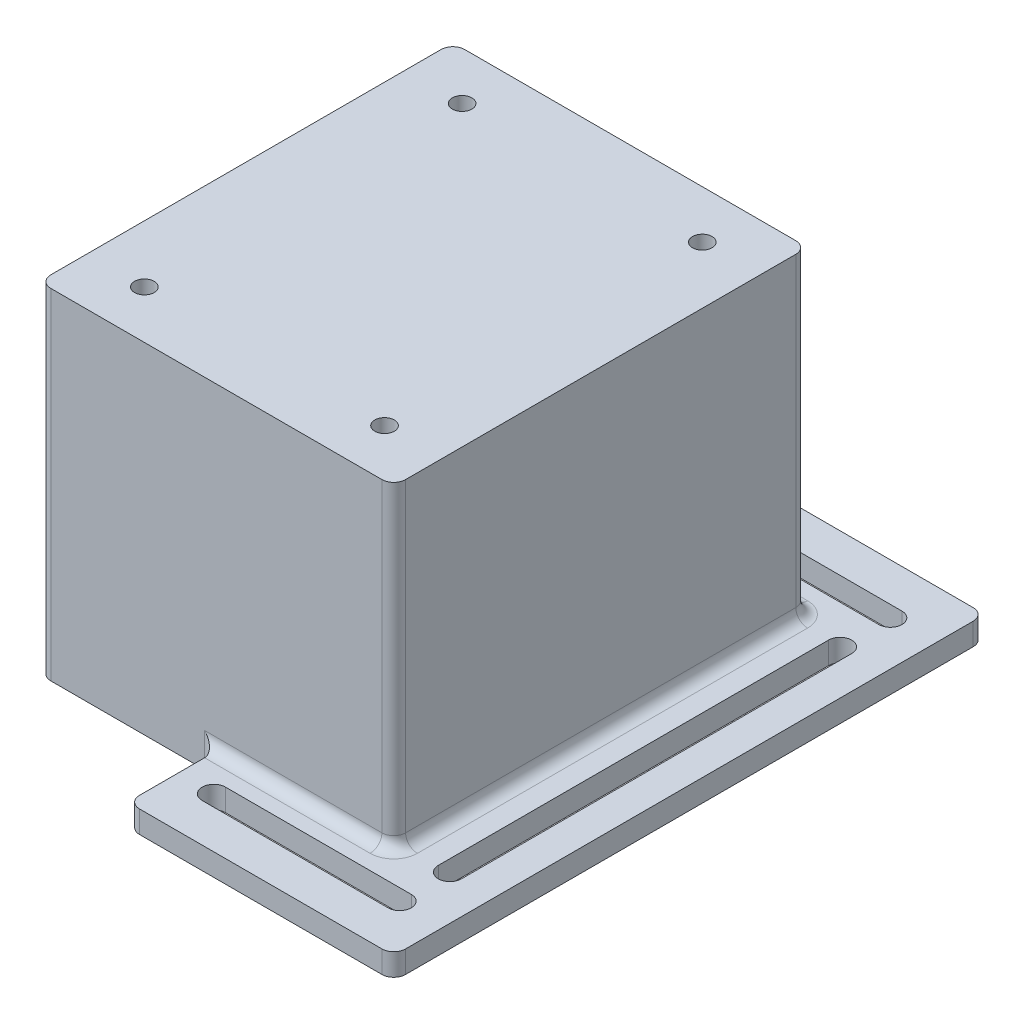
from build123d import *

# Parameters (mm, degrees)
SKETCH1_W           = 76.2
SKETCH1_H           = 88.9
BOSS_EXTRUDE1_DEPTH = 73.025
BOSS_EXTRUDE2_DEPTH = 4.7625
FILLET1_R           = 2.54
CUT_EXTRUDE1_DEPTH  = 5.7625
FILLET2_R           = 2.54
SKETCH4_R           = 2.1
CUT_EXTRUDE2_DEPTH  = 25.4


with BuildPart() as part:
    # Sketch1 → Boss-Extrude1 (new body)
    with BuildSketch(Plane(origin=(0, 0, 0), x_dir=(1, 0, 0), z_dir=(0, 1, 0))):
        with Locations((38.1, 44.45)):
            Rectangle(SKETCH1_W, SKETCH1_H)
    extrude(amount=BOSS_EXTRUDE1_DEPTH)

    # Sketch2 → Boss-Extrude2 (add)
    with BuildSketch(Plane.XZ):
        Polygon((38.1, 0), (38.1, 19.05), (95.25, 19.05), (95.25, -107.95), (38.1, -107.95), (38.1, -88.9), align=None)
    extrude(amount=-BOSS_EXTRUDE2_DEPTH)

    # Fillet1
    fillet1_edges = [part.edges().sort_by_distance(p)[0] for p in [
        (38.1, 2.38125, -107.95),
        (38.1, 2.38125, 19.05),
        (95.25, 2.38125, 19.05),
        (95.25, 2.38125, -107.95),
        (0, 36.5125, -88.9),
        (76.2, 38.89375, -88.9),
        (76.2, 38.89375, 0),
        (0, 36.5125, 0),
    ]]
    fillet(fillet1_edges, radius=FILLET1_R)

    # Sketch3 → Cut-Extrude1 (cut, through all)
    with BuildSketch(Plane(origin=(0, 4.7625, 0), x_dir=(1, 0, 0), z_dir=(0, 1, 0))):
        with BuildLine():
            Line((45.796852287, 99.655), (85.725, 99.655))
            ThreePointArc((85.725, 99.655), (88.225, 97.155), (85.725, 94.655))
            Line((85.725, 94.655), (45.796852287, 94.655))
            ThreePointArc((45.796852287, 94.655), (43.296852287, 97.155), (45.796852287, 99.655))
        make_face()
        with BuildLine():
            Line((45.796852287, -10.755), (85.725, -10.755))
            ThreePointArc((85.725, -10.755), (88.225, -8.255), (85.725, -5.755))
            Line((85.725, -5.755), (45.796852287, -5.755))
            ThreePointArc((45.796852287, -5.755), (43.296852287, -8.255), (45.796852287, -10.755))
        make_face()
        with BuildLine():
            Line((88.225, 86.36), (88.225, 2.54))
            ThreePointArc((88.225, 2.54), (85.725, 0.04), (83.225, 2.54))
            Line((83.225, 2.54), (83.225, 86.36))
            ThreePointArc((83.225, 86.36), (85.725, 88.86), (88.225, 86.36))
        make_face()
    extrude(amount=-CUT_EXTRUDE1_DEPTH, mode=Mode.SUBTRACT)

    # Fillet2
    fillet2_edges = [part.edges().sort_by_distance(p)[0] for p in [
        (55.88, 4.7625, -88.9),
        (38.1, 2.38125, 0),
        (38.1, 2.38125, -88.9),
        (76.2, 4.7625, -44.45),
        (55.88, 4.7625, 0),
        (75.456051224, 4.7625, -88.156051224),
        (75.456051224, 4.7625, -0.743948776),
    ]]
    fillet(fillet2_edges, radius=FILLET2_R)

    # Sketch4 → Cut-Extrude2 (cut)
    with BuildSketch(Plane(origin=(0, 73.025, 0), x_dir=(1, 0, 0), z_dir=(0, 1, 0))):
        with Locations((12.303125, 78.58125)):
            Circle(SKETCH4_R)
        with Locations((12.303125, 10.31875)):
            Circle(SKETCH4_R)
        with Locations((63.896875, 10.31875)):
            Circle(SKETCH4_R)
        with Locations((63.896875, 78.58125)):
            Circle(SKETCH4_R)
    extrude(amount=-CUT_EXTRUDE2_DEPTH, mode=Mode.SUBTRACT)


solid = part.part
